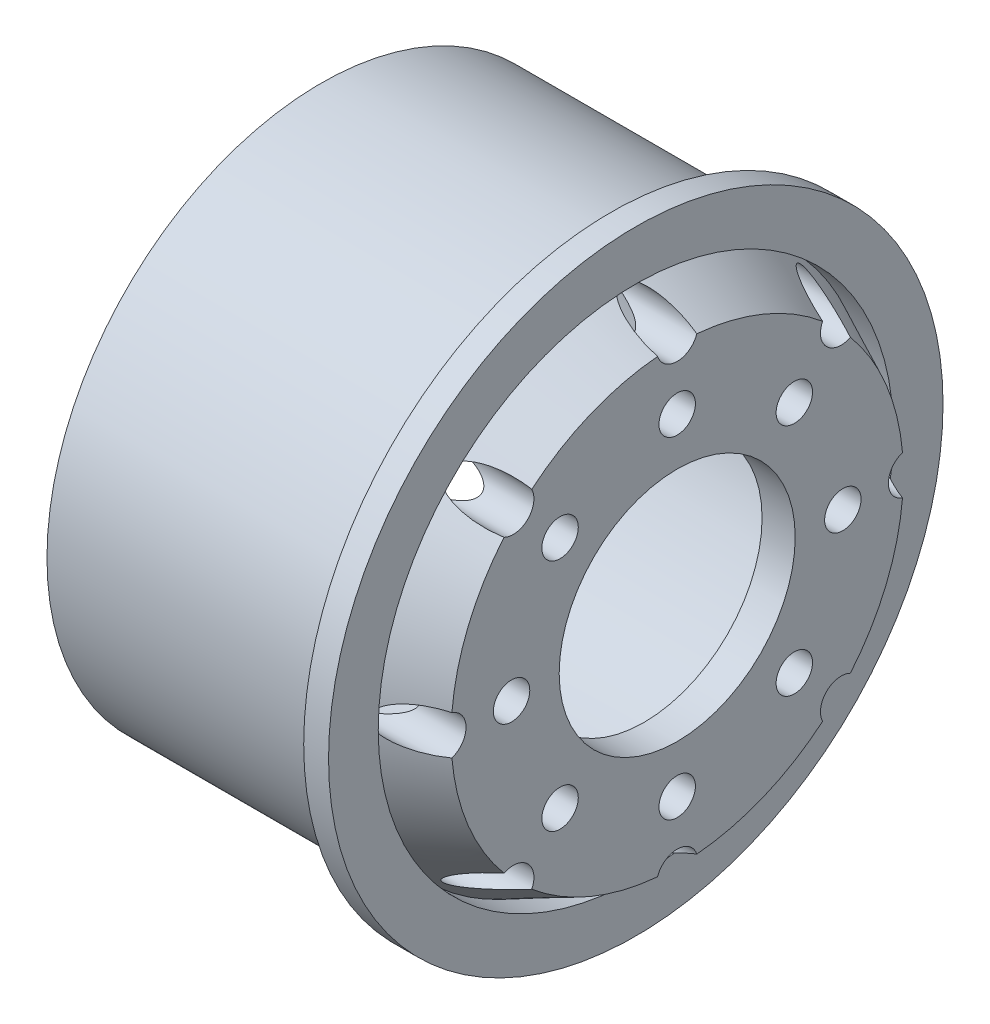
from build123d import *

# Parameters (mm, degrees)
SKETCH2_R          = 1.1
SKETCH2_R_2        = 1.25
CUT_EXTRUDE1_DEPTH = 5


with BuildPart() as part:
    # Sketch1 → Revolve1 (revolve)
    with BuildSketch(Plane(origin=(0, 0, 0), x_dir=(1, 0, 0), z_dir=(0, 1, 0))):
        Polygon((8.936305636, 7.125), (8.936305636, 13.654327145), (4.936305636, 15.55), (6.436305636, 15.55), (6.436305636, 16.55), (6.436305636, 18.55), (4.936305636, 18.55), (4.936305636, 16.55), (-12.563694364, 16.55), (-12.563694364, 14.55), (4.181639858, 13.694418308), (6.936305636, 12.388932023), (6.936305636, 7.125), align=None)
    revolve(axis=Axis((-37.278866169, 0, 0), (1, 0, 0)))

    # Sketch2 → Cut-Extrude1 (cut)
    with BuildSketch(Plane(origin=(8.936305636, 0, 0), x_dir=(0, 0, -1), z_dir=(1, 0, 0))):
        with Locations((0, 10)):
            Circle(SKETCH2_R)
        with Locations((7.071067812, 7.071067812)):
            Circle(SKETCH2_R)
        with Locations((10, 0)):
            Circle(SKETCH2_R)
        with Locations((7.071067812, -7.071067812)):
            Circle(SKETCH2_R)
        with Locations((0, -10)):
            Circle(SKETCH2_R)
        with Locations((-7.071067812, -7.071067812)):
            Circle(SKETCH2_R)
        with Locations((-10, 0)):
            Circle(SKETCH2_R)
        with Locations((-7.071067812, 7.071067812)):
            Circle(SKETCH2_R)
        with Locations((0, -14)):
            Circle(SKETCH2_R_2)
        with Locations((-9.899494937, -9.899494937)):
            Circle(SKETCH2_R_2)
        with Locations((-14, 0)):
            Circle(SKETCH2_R_2)
        with Locations((-9.899494937, 9.899494937)):
            Circle(SKETCH2_R_2)
        with Locations((0, 14)):
            Circle(SKETCH2_R_2)
        with Locations((9.899494937, 9.899494937)):
            Circle(SKETCH2_R_2)
        with Locations((14, 0)):
            Circle(SKETCH2_R_2)
        with Locations((9.899494937, -9.899494937)):
            Circle(SKETCH2_R_2)
    extrude(amount=-CUT_EXTRUDE1_DEPTH, mode=Mode.SUBTRACT)


solid = part.part
